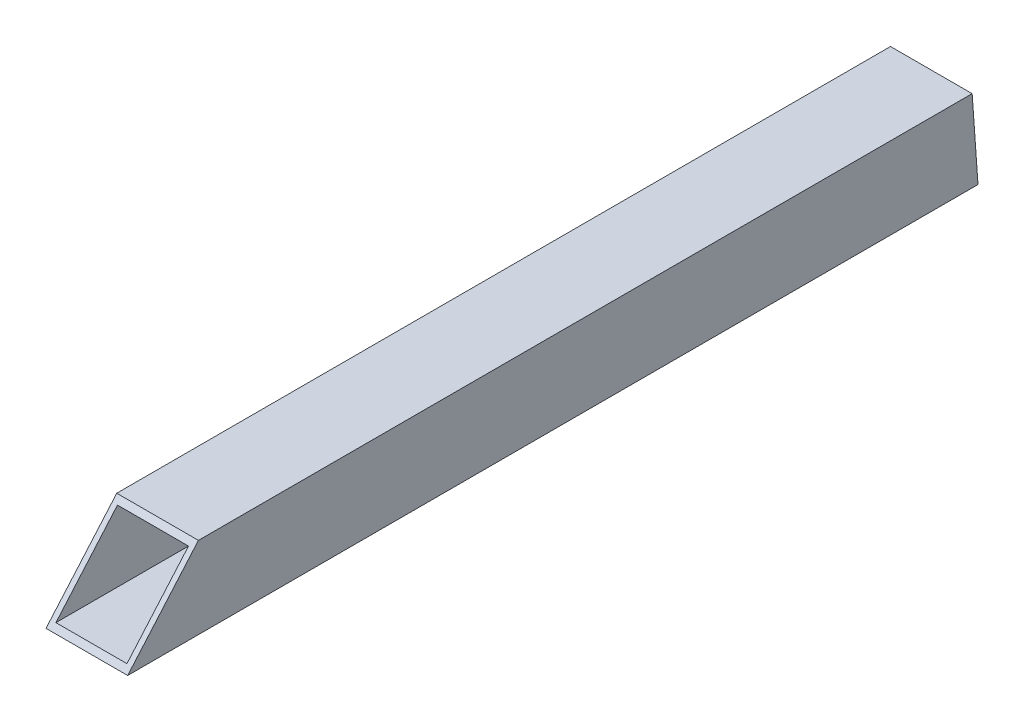
from build123d import *

# Parameters (mm, degrees)
SKETCH1_W           = 25.4
SKETCH1_H           = 25.4
SKETCH1_W_2         = 22.098
SKETCH1_H_2         = 22.098
BOSS_EXTRUDE1_DEPTH = 252.579
SKETCH4_W           = 25.4
SKETCH4_H           = 25.4
SKETCH4_W_2         = 22.098
SKETCH4_H_2         = 22.098
BOSS_EXTRUDE2_DEPTH = 25.4
CUT_EXTRUDE1_DEPTH  = 165.021579309
SKETCH9_W           = 25.4
SKETCH9_H           = 25.4
SKETCH9_W_2         = 22.098
SKETCH9_H_2         = 22.098
BOSS_EXTRUDE4_DEPTH = 25.4
CUT_EXTRUDE2_DEPTH  = 165.021579309


with BuildPart() as part:
    # Sketch1 → Boss-Extrude1 (new body)
    with BuildSketch(Plane.XY):
        Rectangle(SKETCH1_W, SKETCH1_H)
        Rectangle(SKETCH1_W_2, SKETCH1_H_2, mode=Mode.SUBTRACT)
    extrude(amount=BOSS_EXTRUDE1_DEPTH)

    # Sketch4 → Boss-Extrude2 (add)
    with BuildSketch(Plane.XY.offset(252.579)):
        Rectangle(SKETCH4_W, SKETCH4_H)
        Rectangle(SKETCH4_W_2, SKETCH4_H_2, mode=Mode.SUBTRACT)
    extrude(amount=BOSS_EXTRUDE2_DEPTH)

    # Sketch5 → Cut-Extrude1 (cut, through all)
    with BuildSketch(Plane(origin=(151.321579309, -335.991727501, -187.807849157), x_dir=(0, 0.142456183, -0.989801109), z_dir=(-1, 0, 0))):
        Polygon((-345.839515134, -431.854923585), (-430.223070446, -358.746704735), (-433.169492253, -435.100826103), align=None)
    extrude(amount=CUT_EXTRUDE1_DEPTH, mode=Mode.SUBTRACT)

    # Sketch9 → Boss-Extrude4 (add)
    with BuildSketch(Plane(origin=(0, 0, 0), x_dir=(-1, 0, 0), z_dir=(0, 0, -1))):
        Rectangle(SKETCH9_W, SKETCH9_H)
        Rectangle(SKETCH9_W_2, SKETCH9_H_2, mode=Mode.SUBTRACT)
    extrude(amount=BOSS_EXTRUDE4_DEPTH)

    # Sketch10 → Cut-Extrude2 (cut, through all)
    with BuildSketch(Plane(origin=(151.321579309, -335.991727501, -187.807849157), x_dir=(0, 0.142456183, -0.989801109), z_dir=(-1, 0, 0))):
        Polygon((-135.926962008, -388.670724005), (-140.129674812, -329.968023827), (-66.404564793, -354.654811044), align=None)
    extrude(amount=CUT_EXTRUDE2_DEPTH, mode=Mode.SUBTRACT)


solid = part.part
